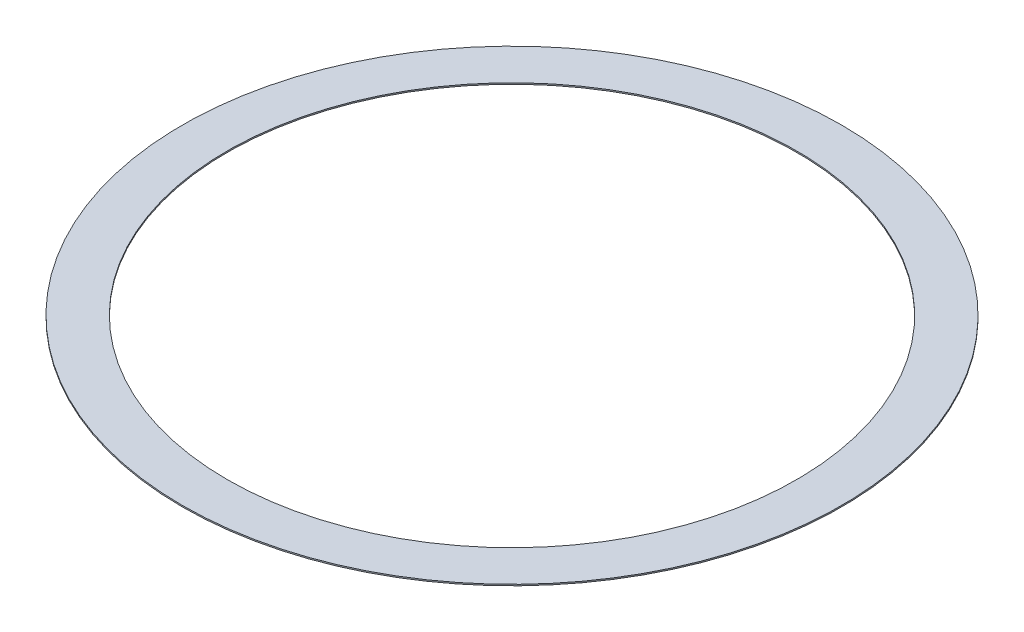
from build123d import *

# Parameters (mm, degrees)
SKETCH1_R           = 25.2095
SKETCH1_R_2         = 21.7805
BOSS_EXTRUDE1_DEPTH = 0.1016


with BuildPart() as part:
    # Sketch1 → Boss-Extrude1 (new body)
    with BuildSketch(Plane(origin=(0, 0, 0), x_dir=(1, 0, 0), z_dir=(0, 1, 0))):
        Circle(SKETCH1_R)
        Circle(SKETCH1_R_2, mode=Mode.SUBTRACT)
    extrude(amount=BOSS_EXTRUDE1_DEPTH)


solid = part.part
